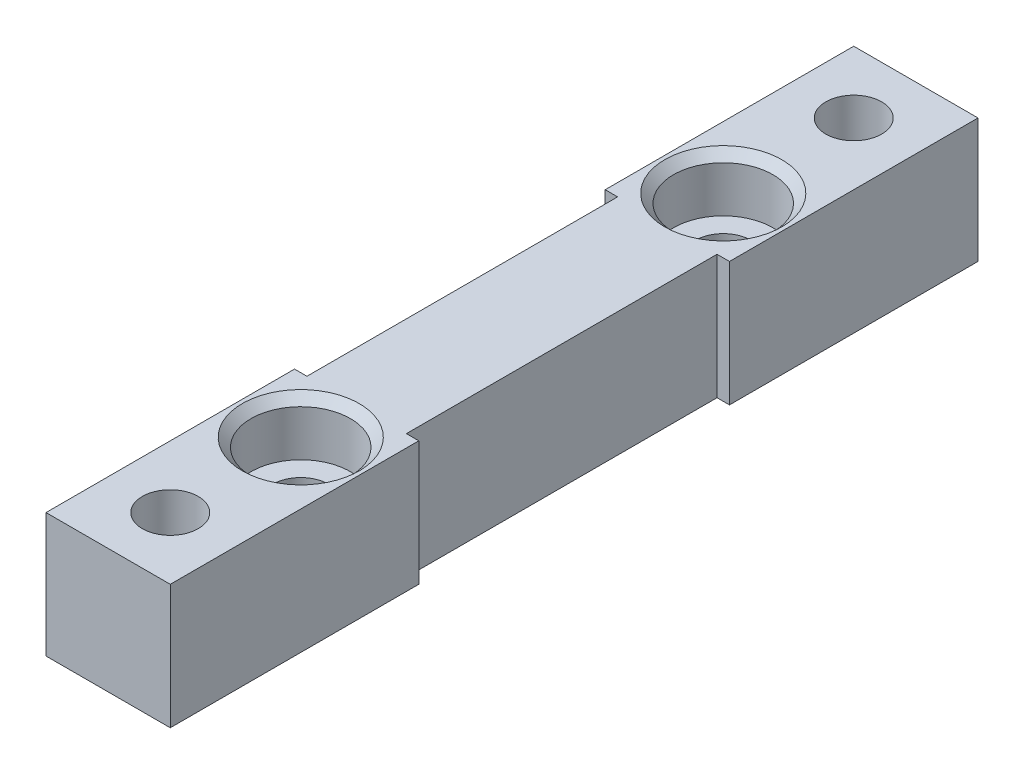
from build123d import *

# Parameters (mm, degrees)
SKETCH_1_W                  = 10
SKETCH_1_H                  = 20
SKETCH_1_W_2                = 8
SKETCH_1_H_2                = 25
EXTRUDE_1_DEPTH             = 10
HOLE_WIZARD_M4_1_AT_2_COUNT = 2
HOLE_WIZARD_M4_1_AT_2_PITCH = 34
HOLE_WIZARD_M4_1_2_D        = 4.5
HOLE_WIZARD_M4_1_2_DEPTH    = 10
SKETCH_7_R                  = 2.25
CUT_EXTRUDE_1_DEPTH         = 4


with BuildPart() as part:
    # 스케치1 → 보스-돌출1 (new body)
    with BuildSketch(Plane(origin=(0, 0, 0), x_dir=(1, 0, 0), z_dir=(0, 1, 0))):
        with Locations((0, 22.5)):
            Rectangle(SKETCH_1_W, SKETCH_1_H)
        Rectangle(SKETCH_1_W_2, SKETCH_1_H_2)
        with Locations((0, -22.5)):
            Rectangle(SKETCH_1_W, SKETCH_1_H)
    extrude(amount=EXTRUDE_1_DEPTH)

    # 스케치3 → Hole Wizard M4 _ _ _ _ _ _1 (revolve, cut)
    with BuildSketch(Plane(origin=(0, 10, -17), x_dir=(0, 0, 1), z_dir=(1, 0, 0))):
        Polygon((0, 0), (0, 10), (2.25, 10), (2.25, 4.4), (4, 4.4), (4, 0.7), (4.7, 0), align=None)
    hole_wizard_m4_1 = revolve(axis=Axis((0, 16.35, -17), (0, -1, 0)), mode=Mode.SUBTRACT)

    # Hole Wizard M4 _ _ _ _ _ _1 at 2: Hole Wizard M4 _ _ _ _ _ _1 ×2
    with Locations(*[(0, 0, i * HOLE_WIZARD_M4_1_AT_2_PITCH) for i in range(1, HOLE_WIZARD_M4_1_AT_2_COUNT)]):
        add(hole_wizard_m4_1, mode=Mode.SUBTRACT)

    # Hole Wizard M4 _ _1 2
    with Locations(Plane(origin=(0, 0, 0), x_dir=(-1, 0, 0), z_dir=(0, -1, 0))):
        with Locations((0, -27.5), (0, 27.5), (54.10839937, -109.42081154)):
            Hole(HOLE_WIZARD_M4_1_2_D / 2, depth=HOLE_WIZARD_M4_1_2_DEPTH)

    # 스케치7 → 컷-돌출1 (cut)
    with BuildSketch(Plane.XZ):
        Polygon((2.049593456, -31.05), (4.099186911, -27.5), (2.049593456, -23.95), (-2.049593456, -23.95), (-4.099186911, -27.5), (-2.049593456, -31.05), align=None)
        with Locations((0, -27.5)):
            Circle(SKETCH_7_R, mode=Mode.SUBTRACT)
        Polygon((2.049593456, 23.95), (-2.049593456, 23.95), (-4.099186911, 27.5), (-2.049593456, 31.05), (2.049593456, 31.05), (4.099186911, 27.5), align=None)
        with Locations((0, 27.5)):
            Circle(SKETCH_7_R, mode=Mode.SUBTRACT)
    extrude(amount=-CUT_EXTRUDE_1_DEPTH, mode=Mode.SUBTRACT)


solid = part.part
